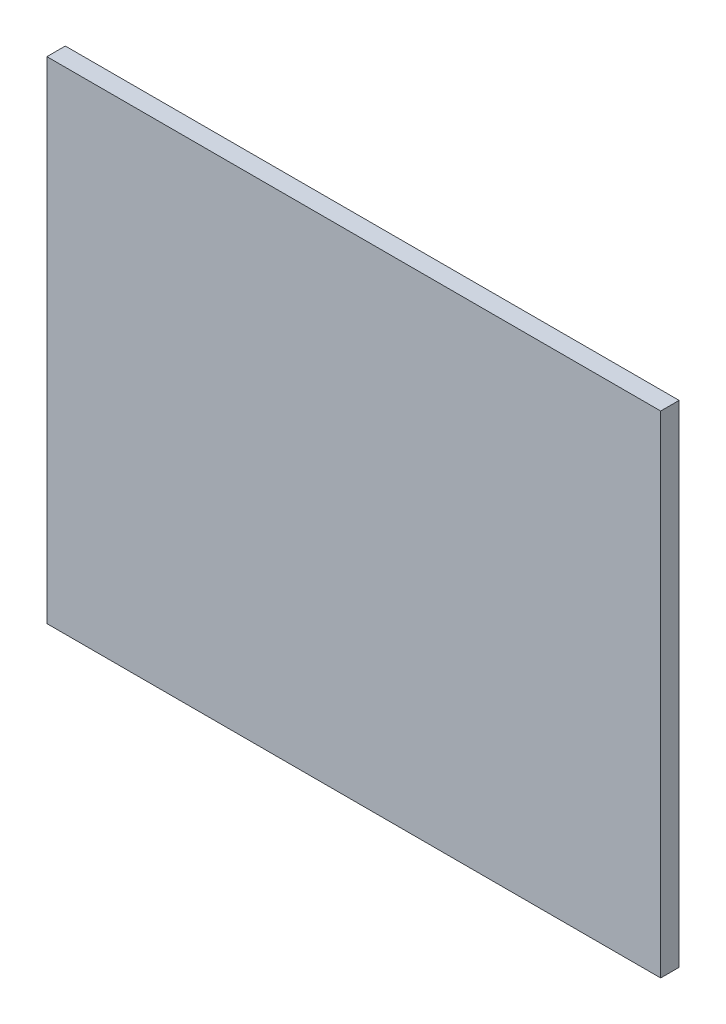
from build123d import *

# Parameters (mm, degrees)
SKICA1_W                 = 100
SKICA1_H                 = 80
P_IDAT_VYSUNUT_M1_DEPTH  = 3
ODEBRAT_START            = -0.4
SKICA2_R                 = 3
ODEBRAT_VYSUNUT_M1_DEPTH = 1.4


with BuildPart() as part:
    # Skica1 → Přidat vysunutím1 (new body)
    with BuildSketch(Plane.XY):
        with Locations((50, 40)):
            Rectangle(SKICA1_W, SKICA1_H)
    extrude(amount=P_IDAT_VYSUNUT_M1_DEPTH)

    # Skica2 → Odebrat vysunutím1 (cut)
    with BuildSketch(Plane.XY.offset(3).offset(ODEBRAT_START)):
        with Locations((4, 76)):
            Circle(SKICA2_R)
        with Locations((96, 76)):
            Circle(SKICA2_R)
        with Locations((96, 4)):
            Circle(SKICA2_R)
        with Locations((4, 4)):
            Circle(SKICA2_R)
    extrude(amount=-ODEBRAT_VYSUNUT_M1_DEPTH, mode=Mode.SUBTRACT)


solid = part.part
